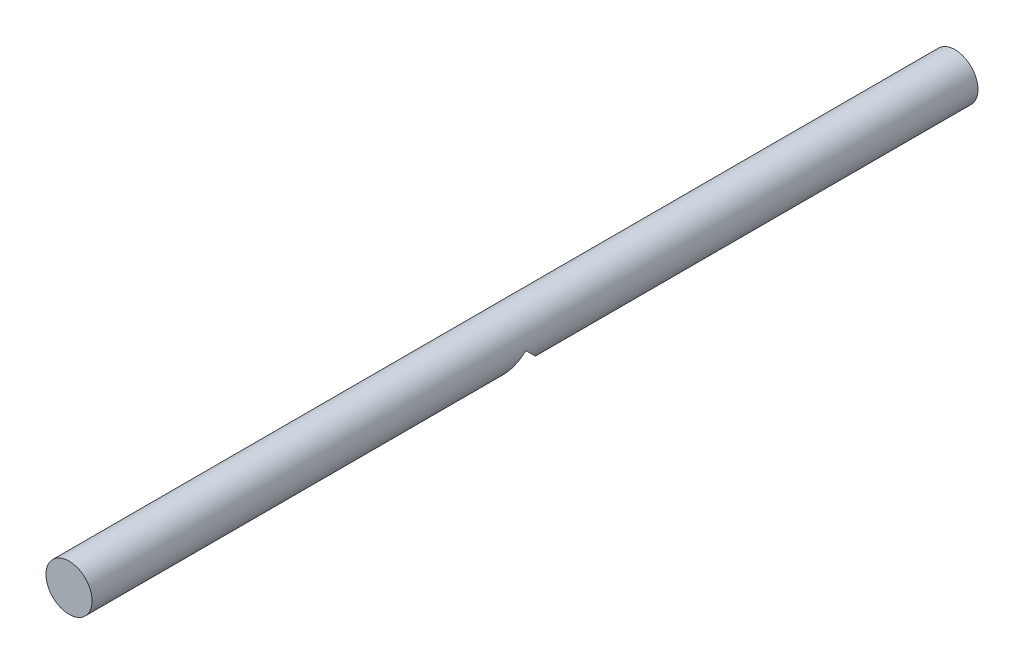
from build123d import *

# Parameters (mm, degrees)
SKETCH1_R           = 12.5
BOSS_EXTRUDE1_DEPTH = 480
SKETCH2_R           = 12.5
CUT_EXTRUDE3_DEPTH  = 20


with BuildPart() as part:
    # Sketch1 → Boss-Extrude1 (new body)
    with BuildSketch(Plane.XY):
        Circle(SKETCH1_R)
    extrude(amount=BOSS_EXTRUDE1_DEPTH)

    # Sketch2 → Cut-Extrude3 (cut)
    with BuildSketch(Plane(origin=(0, 0, 0), x_dir=(1, 0, 0), z_dir=(0, 1, 0))):
        with Locations((0, -245)):
            Circle(SKETCH2_R)
    extrude(amount=-CUT_EXTRUDE3_DEPTH, mode=Mode.SUBTRACT)


solid = part.part
